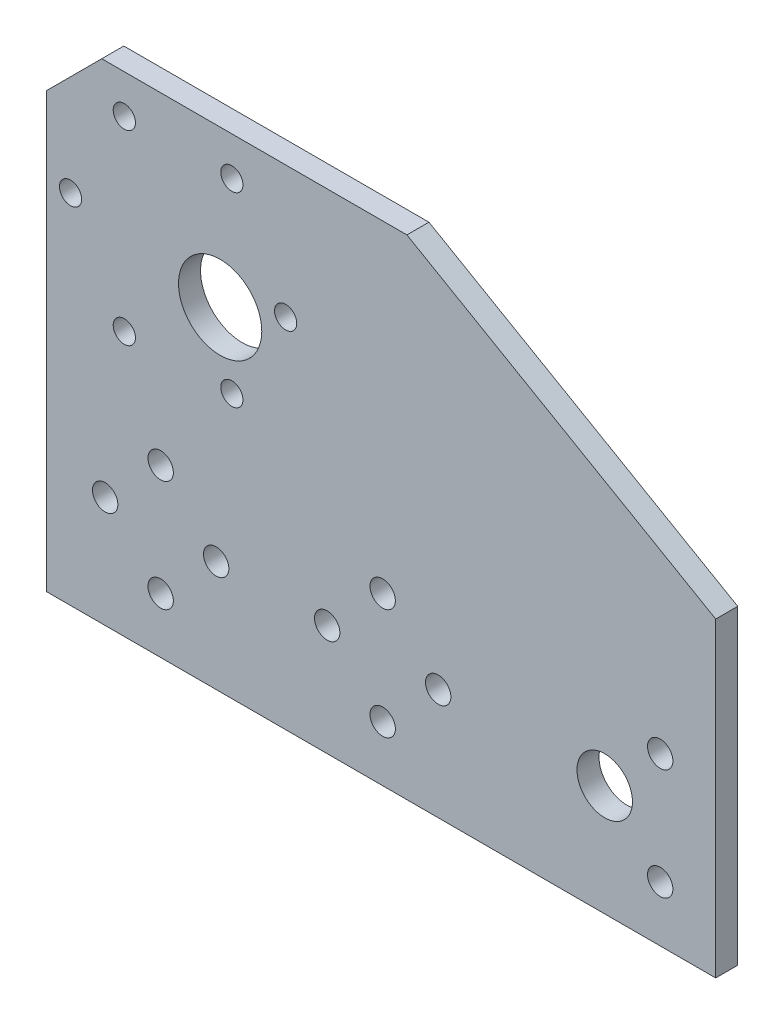
from build123d import *

# Parameters (mm, degrees)
SKETCH1_R                  = 4
BOSS_EXTRUDE1_DEPTH        = 3.175
M3_CLEARANCE_HOLE1_D       = 3.2
F_12_0_12_DIAMETER_HOLE1_D = 12
F_6_CLEARANCE_HOLE2_D      = 3.6576
F_6_CLEARANCE_HOLE1_D      = 3.6576


with BuildPart() as part:
    # Sketch1 → Boss-Extrude1 (new body)
    with BuildSketch(Plane.XY):
        Polygon((16, -16), (-80.487803669, -16), (-80.487803669, 46.5), (-72.487803669, 54.5), (-28.507138544, 54.5), (16, 28.803791581), align=None)
        Circle(SKETCH1_R, mode=Mode.SUBTRACT)
    extrude(amount=-BOSS_EXTRUDE1_DEPTH)

    # M3 Clearance Hole1 (through all)
    with Locations(Plane.XY):
        with Locations((-69.237803669, 48.923393759), (-53.737803669, 48.923393759), (-45.987803669, 35.5), (-53.737803669, 22.076606241), (-69.237803669, 22.076606241), (-76.987803669, 35.5)):
            Hole(M3_CLEARANCE_HOLE1_D / 2)

    # Ø12.0 (12) Diameter Hole1 (through all)
    with Locations(Plane.XY):
        with Locations((-55.425625842, 32)):
            Hole(F_12_0_12_DIAMETER_HOLE1_D / 2)

    # 6 Clearance Hole2 (through all)
    with Locations(Plane.XY):
        with Locations((-72, 0), (-32, -8), (-64, -8)):
            Hole(F_6_CLEARANCE_HOLE2_D / 2)

    # 6 Clearance Hole1 (through all)
    with Locations(Plane.XY):
        with Locations((-32, 8), (-24, 0), (-64, 8), (-56, 0), (-40, 0), (8, 8), (8, -8)):
            Hole(F_6_CLEARANCE_HOLE1_D / 2)


solid = part.part
